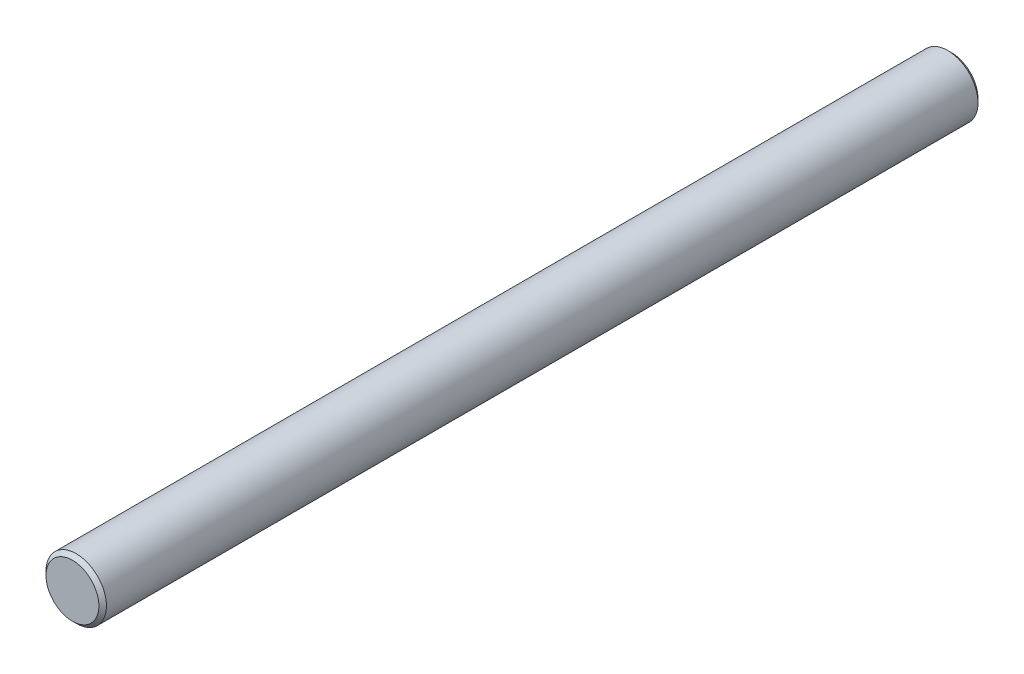
from build123d import *

# Parameters (mm, degrees)
CHAMFER1_SIZE         = 0.5
CHAMFER2_SIZE         = 0.3
CHAMFER2_SIZE2        = 0.173205081
CHAMFER2_PART_2_SIZE  = 0.3
CHAMFER2_PART_2_SIZE2 = 0.173205081
CHAMFER2_PART_3_SIZE  = 0.3
CHAMFER2_PART_3_SIZE2 = 0.173205081
CHAMFER2_PART_4_SIZE  = 0.3
CHAMFER2_PART_4_SIZE2 = 0.173205081
SKETCH2_W             = 23.197150539
SKETCH2_H             = 11.802059046
CUT_EXTRUDE1_DEPTH    = 50
CHAMFER3_SIZE         = 0.5


with BuildPart() as part:
    # Sketch1 → Revolve1 (revolve)
    with BuildSketch(Plane(origin=(0, 0, 0), x_dir=(1, 0, 0), z_dir=(0, 1, 0))):
        Polygon((-1, 0), (-4, 0), (-4, -121), (-1, -121), (-1, -119), (0, -119), (0, -2), (-1, -2), align=None)
    revolve(axis=Axis((0, 0, 119), (0, 0, -1)))

    # Chamfer1
    chamfer1_edges = [part.edges().sort_by_distance(p)[0] for p in [
        (4, 0, 121),
        (4, 0, 0),
    ]]
    chamfer(chamfer1_edges, length=CHAMFER1_SIZE)

    # Chamfer2
    chamfer2_edges = [part.edges().sort_by_distance(p)[0] for p in [
        (1, 0, 2),
    ]]
    chamfer2_side = [part.faces().sort_by_distance(p)[0] for p in [
        (0, 0, 2),
    ]]
    chamfer(chamfer2_edges, length=CHAMFER2_SIZE, length2=CHAMFER2_SIZE2, reference=chamfer2_side[0])

    # Chamfer2 part 2
    chamfer2_part_2_edges = [part.edges().sort_by_distance(p)[0] for p in [
        (1, 0, 119),
    ]]
    chamfer2_part_2_side = [part.faces().sort_by_distance(p)[0] for p in [
        (1, 0, 120),
    ]]
    chamfer(chamfer2_part_2_edges, length=CHAMFER2_PART_2_SIZE, length2=CHAMFER2_PART_2_SIZE2, reference=chamfer2_part_2_side[0])

    # Chamfer2 part 3
    chamfer2_part_3_edges = [part.edges().sort_by_distance(p)[0] for p in [
        (1, 0, 121),
    ]]
    chamfer2_part_3_side = [part.faces().sort_by_distance(p)[0] for p in [
        (3.401005051, 0, 121),
    ]]
    chamfer(chamfer2_part_3_edges, length=CHAMFER2_PART_3_SIZE, length2=CHAMFER2_PART_3_SIZE2, reference=chamfer2_part_3_side[0])

    # Chamfer2 part 4
    chamfer2_part_4_edges = [part.edges().sort_by_distance(p)[0] for p in [
        (1, 0, 0),
    ]]
    chamfer2_part_4_side = [part.faces().sort_by_distance(p)[0] for p in [
        (1, 0, 1),
    ]]
    chamfer(chamfer2_part_4_edges, length=CHAMFER2_PART_4_SIZE, length2=CHAMFER2_PART_4_SIZE2, reference=chamfer2_part_4_side[0])

    # Sketch2 → Cut-Extrude1 (cut)
    with BuildSketch(Plane(origin=(0, 28.2, 0), x_dir=(1, 0, 0), z_dir=(0, 1, 0))):
        with Locations((2.541571207, -122.251029523)):
            Rectangle(SKETCH2_W, SKETCH2_H)
    extrude(amount=-CUT_EXTRUDE1_DEPTH, mode=Mode.SUBTRACT)

    # Chamfer3
    chamfer3_edges = [part.edges().sort_by_distance(p)[0] for p in [
        (4, 0, 116.35),
    ]]
    chamfer(chamfer3_edges, length=CHAMFER3_SIZE)


solid = part.part
